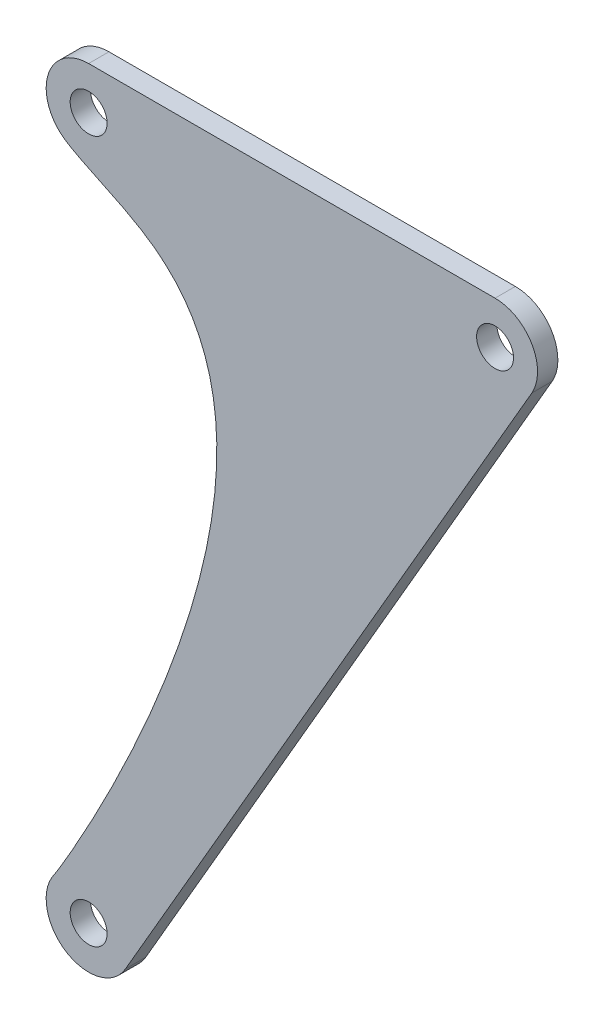
from build123d import *

# Parameters (mm, degrees)
SKETCH1_R           = 5
BOSS_EXTRUDE1_DEPTH = 2.75


with BuildPart() as part:
    # Sketch1 → Boss-Extrude1 (new body, symmetric)
    with BuildSketch(Plane.XY):
        with BuildLine():
            Line((-110, 11.5), (0, 11.5))
            ThreePointArc((0, 11.5), (9.962731723, 5.744038354), (9.952402283, -5.761917111))
            Line((9.952402283, -5.761917111), (-100.047597717, -195.761917111))
            ThreePointArc((-100.047597717, -195.761917111), (-116.313869125, -199.611714554), (-119.240449643, -183.154264802))
            add(Edge.make_bspline(
                [(-117.582652102, -8.646004111), (-113.500583089, -12.226028917), (-89.343136838, -20.249723308), (-54.529955021, -76.69947908), (-117.517833386, -180.829058186), (-119.240449643, -183.154264802)],
                knots=[0, 0, 0, 0, 0.138535768, 0.282875599, 1, 1, 1, 1], degree=3))
            ThreePointArc((-117.582652102, -8.646004111), (-120.762877108, 4.050984616), (-110, 11.5))
        make_face()
        Circle(SKETCH1_R, mode=Mode.SUBTRACT)
        with Locations((-110, -190)):
            Circle(SKETCH1_R, mode=Mode.SUBTRACT)
        with Locations((-110, 0)):
            Circle(SKETCH1_R, mode=Mode.SUBTRACT)
    extrude(amount=BOSS_EXTRUDE1_DEPTH, both=True)


solid = part.part
